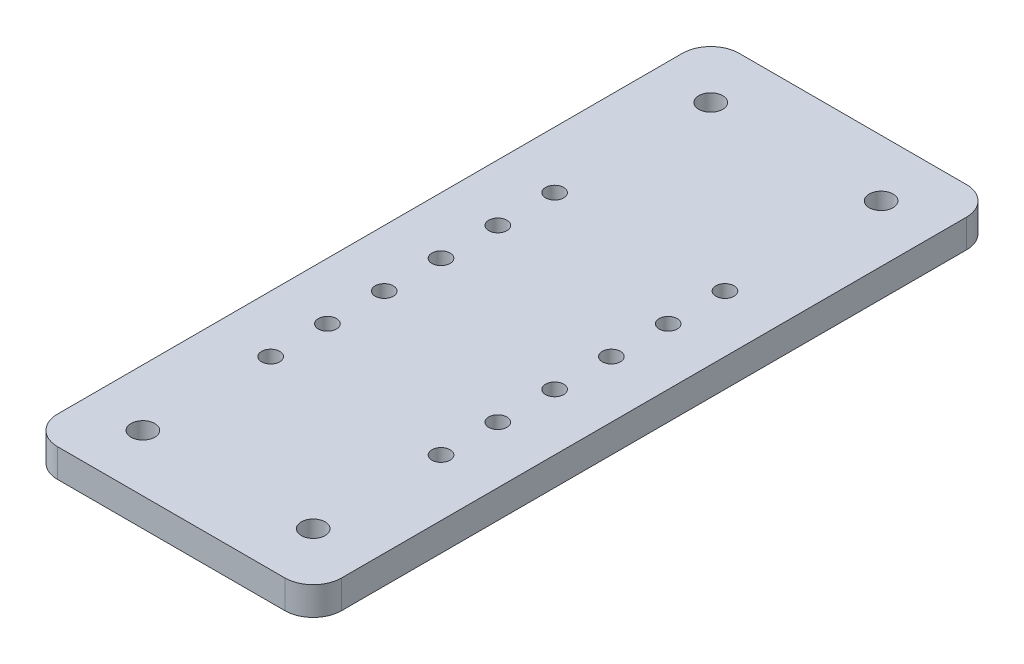
from build123d import *

# Parameters (mm, degrees)
SKETCH1_W           = 50
SKETCH1_H           = 120
SKETCH1_R           = 2.1
SKETCH1_R_2         = 1.6
BOSS_EXTRUDE1_DEPTH = 5
FILLET2_R           = 5


with BuildPart() as part:
    # Sketch1 → Boss-Extrude1 (new body)
    with BuildSketch(Plane(origin=(0, 0, 0), x_dir=(1, 0, 0), z_dir=(0, 1, 0))):
        Rectangle(SKETCH1_W, SKETCH1_H)
        with Locations((-15, 50)):
            Circle(SKETCH1_R, mode=Mode.SUBTRACT)
        with Locations((15, 50)):
            Circle(SKETCH1_R, mode=Mode.SUBTRACT)
        with Locations((15, 22.5)):
            Circle(SKETCH1_R_2, mode=Mode.SUBTRACT)
        with Locations((-15, -27.5)):
            Circle(SKETCH1_R_2, mode=Mode.SUBTRACT)
        with Locations((-15, -17.5)):
            Circle(SKETCH1_R_2, mode=Mode.SUBTRACT)
        with Locations((-15, -7.5)):
            Circle(SKETCH1_R_2, mode=Mode.SUBTRACT)
        with Locations((15, -27.5)):
            Circle(SKETCH1_R_2, mode=Mode.SUBTRACT)
        with Locations((15, -17.5)):
            Circle(SKETCH1_R_2, mode=Mode.SUBTRACT)
        with Locations((15, -7.5)):
            Circle(SKETCH1_R_2, mode=Mode.SUBTRACT)
        with Locations((-15, 2.5)):
            Circle(SKETCH1_R_2, mode=Mode.SUBTRACT)
        with Locations((-15, 12.5)):
            Circle(SKETCH1_R_2, mode=Mode.SUBTRACT)
        with Locations((-15, 22.5)):
            Circle(SKETCH1_R_2, mode=Mode.SUBTRACT)
        with Locations((15, 2.5)):
            Circle(SKETCH1_R_2, mode=Mode.SUBTRACT)
        with Locations((15, 12.5)):
            Circle(SKETCH1_R_2, mode=Mode.SUBTRACT)
        with Locations((15, -50)):
            Circle(SKETCH1_R, mode=Mode.SUBTRACT)
        with Locations((-15, -50)):
            Circle(SKETCH1_R, mode=Mode.SUBTRACT)
    extrude(amount=BOSS_EXTRUDE1_DEPTH)

    # Fillet2
    fillet2_edges = [part.edges().sort_by_distance(p)[0] for p in [
        (25, 2.5, 60),
        (-25, 2.5, 60),
        (-25, 2.5, -60),
        (25, 2.5, -60),
    ]]
    fillet(fillet2_edges, radius=FILLET2_R)


solid = part.part
